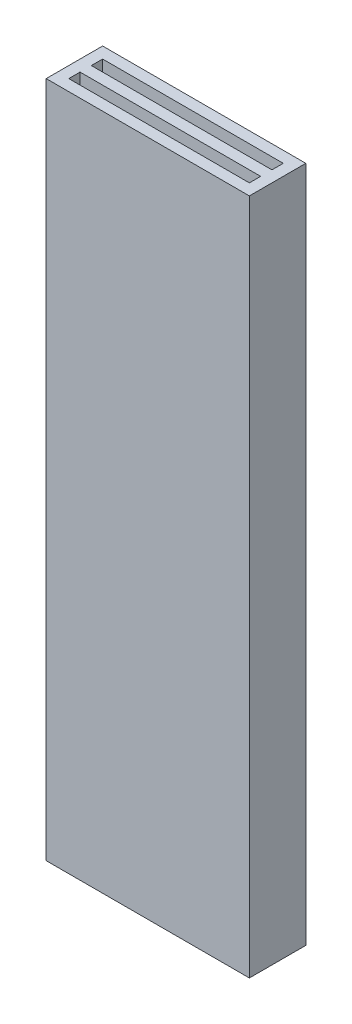
from build123d import *

# Parameters (mm, degrees)
SKETCH1_W           = 9
SKETCH1_H           = 2.5
BOSS_EXTRUDE1_DEPTH = 15
CUT_EXTRUDE1_START  = -31
SKETCH2_W           = 8
SKETCH2_H           = 0.5
CUT_EXTRUDE1_DEPTH  = 32


with BuildPart() as part:
    # Sketch1 → Boss-Extrude1 (new body, symmetric)
    with BuildSketch(Plane(origin=(0, 0, 0), x_dir=(1, 0, 0), z_dir=(0, 1, 0))):
        Rectangle(SKETCH1_W, SKETCH1_H)
    extrude(amount=BOSS_EXTRUDE1_DEPTH, both=True)

    # Sketch2 → Cut-Extrude1 (cut)
    with BuildSketch(Plane(origin=(0, 15, 0), x_dir=(1, 0, 0), z_dir=(0, 1, 0)).offset(CUT_EXTRUDE1_START)):
        with Locations((0, 0.5)):
            Rectangle(SKETCH2_W, SKETCH2_H)
    cut_extrude1 = extrude(amount=CUT_EXTRUDE1_DEPTH, mode=Mode.SUBTRACT)

    # Mirror1: Cut-Extrude1 across plane
    add(cut_extrude1.mirror(Plane.XY), mode=Mode.SUBTRACT)


solid = part.part
